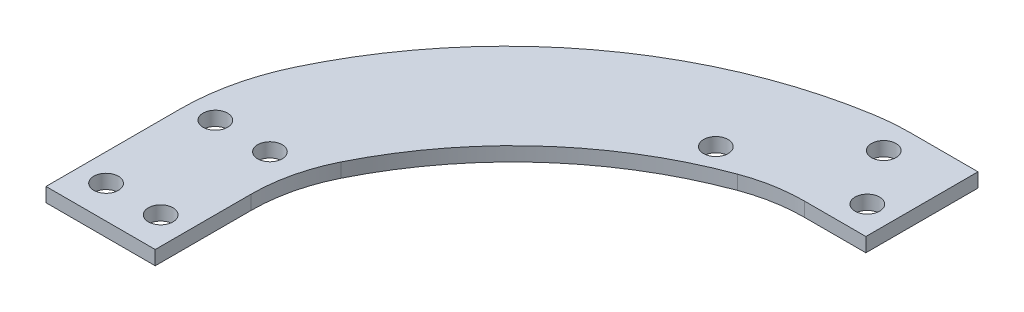
from build123d import *

# Parameters (mm, degrees)
BOSS_EXTRUDE1_DEPTH      = 2.58826
M4_CLEARANCE_HOLE1_D     = 4.5
M4_CLEARANCE_HOLE2_D     = 4.5
M4_CLEARANCE_HOLE3_D     = 4.5
M4_CLEARANCE_HOLE3_DEPTH = 12.45
M4_CLEARANCE_HOLE3_TIP   = 1.351936393


with BuildPart() as part:
    # Sketch1 → Boss-Extrude1 (new body)
    with BuildSketch(Plane(origin=(0, 0, 0), x_dir=(1, 0, 0), z_dir=(0, 1, 0))):
        with BuildLine():
            Line((-10, -16), (10, -16))
            Line((10, -16), (10, 1.571108341))
            ThreePointArc((10, 1.571108341), (10.790342052, 8.411859949), (13.119725505, 14.89217598))
            ThreePointArc((13.119725505, 14.89217598), (28.94391879, 35.737554133), (51.350094649, 49.261539007))
            ThreePointArc((51.350094649, 49.261539007), (56.465127412, 50.651730141), (61.744986775, 51.12))
            Line((61.744986775, 51.12), (73, 51.12))
            Line((73, 51.12), (73, 71.65))
            Line((73, 71.65), (60.729747862, 71.65))
            ThreePointArc((60.729747862, 71.65), (57.460315443, 71.516161236), (54.212761864, 71.115540583))
            ThreePointArc((54.212761864, 71.115540583), (18.477348074, 55.823044348), (-6.115833148, 25.722285599))
            ThreePointArc((-6.115833148, 25.722285599), (-9.016876643, 17.34172385), (-10, 8.527908726))
            Line((-10, 8.527908726), (-10, -16))
        make_face()
    extrude(amount=BOSS_EXTRUDE1_DEPTH)

    # M4 Clearance Hole1 (through all)
    with Locations(Plane(origin=(0, 2.58826, 0), x_dir=(1, 0, 0), z_dir=(0, 1, 0))):
        with Locations((-5, 10), (5, 10), (5, -10), (-5, -10)):
            Hole(M4_CLEARANCE_HOLE1_D / 2)

    # M4 Clearance Hole2 (through all)
    with Locations(Plane(origin=(0, 2.58826, 0), x_dir=(1, 0, 0), z_dir=(0, 1, 0))):
        with Locations((61, 66.385), (68, 56.385)):
            Hole(M4_CLEARANCE_HOLE2_D / 2)

    # M4 Clearance Hole3
    with Locations(Plane(origin=(0, 0, 0), x_dir=(-1, 0, 0), z_dir=(0, -1, 0))):
        with Locations((-45, 51.65)):
            Hole(M4_CLEARANCE_HOLE3_D / 2, depth=M4_CLEARANCE_HOLE3_DEPTH)
            with Locations((0, 0, -(M4_CLEARANCE_HOLE3_DEPTH + M4_CLEARANCE_HOLE3_TIP / 2))):  # 118° drill point
                Cone(0, M4_CLEARANCE_HOLE3_D / 2, M4_CLEARANCE_HOLE3_TIP, mode=Mode.SUBTRACT)


solid = part.part
